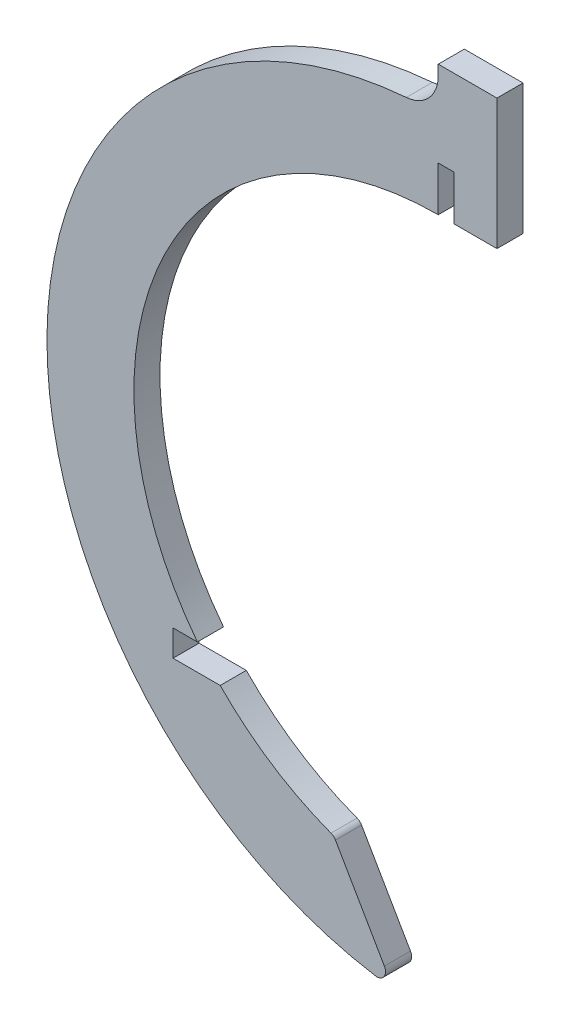
from build123d import *

# Parameters (mm, degrees)
BOSS_EXTRUDE1_DEPTH = 3
FILLET1_R           = 4
FILLET2_R           = 1
FILLET3_R           = 1
SKETCH2_W           = 68.766076313
SKETCH2_H           = 3.02
CUT_EXTRUDE3_DEPTH  = 10
SKETCH3_W           = 3.5
SKETCH3_H           = 3.02
BOSS_EXTRUDE2_DEPTH = 3


with BuildPart() as part:
    # Sketch1 → Boss-Extrude1 (new body)
    with BuildSketch(Plane.XY):
        with BuildLine():
            Line((0, 35), (0, 40.154947939))
            Line((0, 40.154947939), (1.79, 40.154947939))
            Line((1.79, 40.154947939), (1.79, 35))
            Line((1.79, 35), (6.75, 35))
            Line((6.75, 35), (6.75, 50))
            Line((6.75, 50), (0, 50))
            Line((0, 50), (0, 45))
            ThreePointArc((0, 45), (-44.925333381, 2.591219899), (-5.173840791, -44.701581308))
            Line((-5.173840791, -44.701581308), (-11.99982612, -32.878627908))
            ThreePointArc((-11.99982612, -32.878627908), (-34.465576861, 6.092947695), (0, 35))
        make_face()
    extrude(amount=BOSS_EXTRUDE1_DEPTH)

    # Fillet1
    fillet1_edges = [part.edges().sort_by_distance(p)[0] for p in [
        (0, 45, 1.5),
    ]]
    fillet(fillet1_edges, radius=FILLET1_R)

    # Fillet2
    fillet2_edges = [part.edges().sort_by_distance(p)[0] for p in [
        (-5.173840791, -44.701581308, 1.5),
    ]]
    fillet(fillet2_edges, radius=FILLET2_R)

    # Fillet3
    fillet3_edges = [part.edges().sort_by_distance(p)[0] for p in [
        (-11.99982612, -32.878627908, 1.5),
    ]]
    fillet(fillet3_edges, radius=FILLET3_R)

    # Sketch2 → Cut-Extrude3 (cut)
    with BuildSketch(Plane.XY.offset(3)):
        with Locations((0.383038156, -22.906441492)):
            Rectangle(SKETCH2_W, SKETCH2_H)
    extrude(amount=-CUT_EXTRUDE3_DEPTH, mode=Mode.SUBTRACT)

    # Sketch3 → Boss-Extrude2 (add)
    with BuildSketch(Plane.XY.offset(3)):
        with Locations((-32.25, -22.906441492)):
            Rectangle(SKETCH3_W, SKETCH3_H)
    extrude(amount=-BOSS_EXTRUDE2_DEPTH)


solid = part.part
